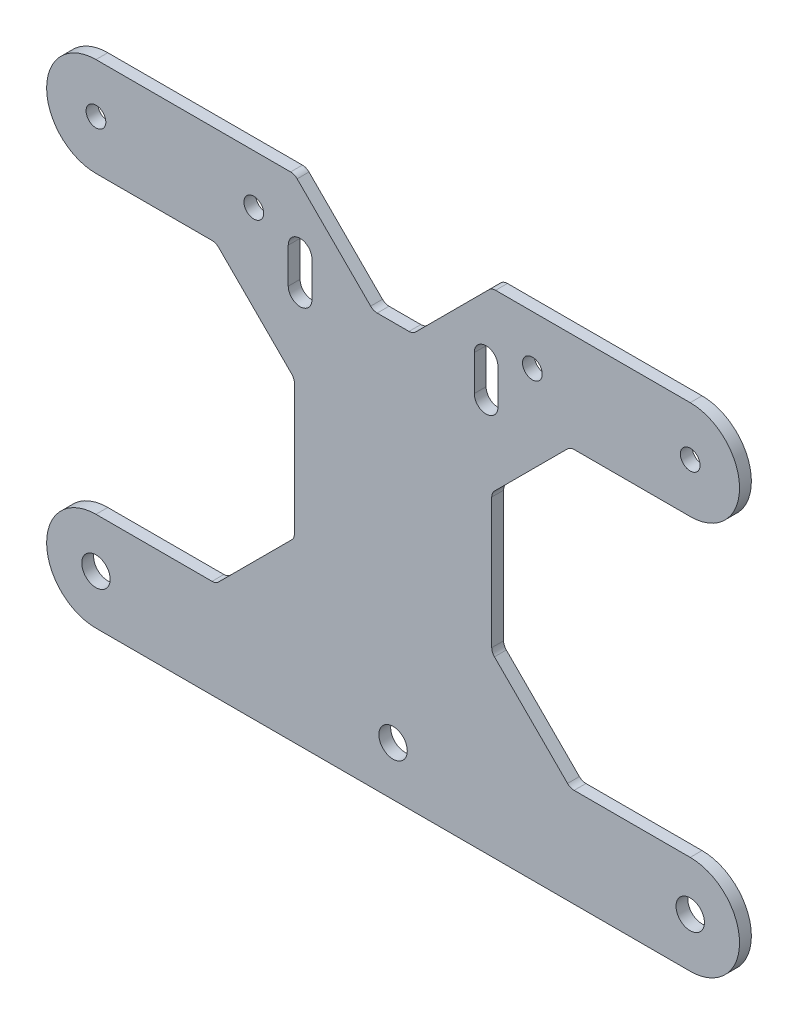
from build123d import *

# Parameters (mm, degrees)
MODEL_R             = 3.6
MODEL_R_2           = 2.5
BOSS_EXTRUDE1_DEPTH = 3


with BuildPart() as part:
    # Model → Boss-Extrude1 (new body)
    with BuildSketch(Plane.XY):
        with BuildLine():
            Line((-75.3, 0), (75.3, 0))
            ThreePointArc((75.3, 0), (87.8, 12.5), (75.3, 25))
            Line((75.3, 25), (45.873401872, 25))
            ThreePointArc((45.873401872, 25), (44.974095806, 25.178883099), (44.211700936, 25.688299064))
            Line((44.211700936, 25.688299064), (25.688299064, 44.211700936))
            ThreePointArc((25.688299064, 44.211700936), (25.178883099, 44.974095805), (25, 45.873401872))
            Line((25, 45.873401872), (25, 78.926598129))
            ThreePointArc((25, 78.926598129), (25.178883099, 79.825904195), (25.688299064, 80.588299064))
            Line((25.688299064, 80.588299064), (44.211700936, 99.111700936))
            ThreePointArc((44.211700936, 99.111700936), (44.974095806, 99.621116901), (45.873401872, 99.8))
            Line((45.873401872, 99.8), (75.3, 99.8))
            ThreePointArc((75.3, 99.8), (87.8, 112.3), (75.3, 124.8))
            Line((75.3, 124.8), (25.973401872, 124.8))
            ThreePointArc((25.973401872, 124.8), (25.074095806, 124.621116901), (24.311700936, 124.111700936))
            Line((24.311700936, 124.111700936), (5.688299064, 105.488299064))
            ThreePointArc((5.688299064, 105.488299064), (4.925904195, 104.978883099), (4.026598129, 104.8))
            Line((4.026598129, 104.8), (-4.026598129, 104.8))
            ThreePointArc((-4.026598129, 104.8), (-4.925904195, 104.978883099), (-5.688299064, 105.488299064))
            Line((-5.688299064, 105.488299064), (-24.311700936, 124.111700936))
            ThreePointArc((-24.311700936, 124.111700936), (-25.074095806, 124.621116901), (-25.973401872, 124.8))
            Line((-25.973401872, 124.8), (-75.3, 124.8))
            ThreePointArc((-75.3, 124.8), (-87.8, 112.3), (-75.3, 99.8))
            Line((-75.3, 99.8), (-45.873401872, 99.8))
            ThreePointArc((-45.873401872, 99.8), (-44.974095806, 99.621116901), (-44.211700936, 99.111700936))
            Line((-44.211700936, 99.111700936), (-25.688299064, 80.588299064))
            ThreePointArc((-25.688299064, 80.588299064), (-25.178883099, 79.825904195), (-25, 78.926598129))
            Line((-25, 78.926598129), (-25, 45.873401872))
            ThreePointArc((-25, 45.873401872), (-25.178883099, 44.974095805), (-25.688299064, 44.211700936))
            Line((-25.688299064, 44.211700936), (-44.211700936, 25.688299064))
            ThreePointArc((-44.211700936, 25.688299064), (-44.974095806, 25.178883099), (-45.873401872, 25))
            Line((-45.873401872, 25), (-75.3, 25))
            ThreePointArc((-75.3, 25), (-87.8, 12.5), (-75.3, 0))
        make_face()
        with Locations((75.3, 12.5)):
            Circle(MODEL_R, mode=Mode.SUBTRACT)
        with Locations((0, 12.5)):
            Circle(MODEL_R, mode=Mode.SUBTRACT)
        with Locations((-75.3, 12.5)):
            Circle(MODEL_R, mode=Mode.SUBTRACT)
        with Locations((-35.3, 112.3)):
            Circle(MODEL_R_2, mode=Mode.SUBTRACT)
        with Locations((-75.3, 112.3)):
            Circle(MODEL_R_2, mode=Mode.SUBTRACT)
        with Locations((35.3, 112.3)):
            Circle(MODEL_R_2, mode=Mode.SUBTRACT)
        with Locations((75.3, 112.3)):
            Circle(MODEL_R_2, mode=Mode.SUBTRACT)
        with BuildLine():
            Line((26.57, 99.43), (26.57, 108.43))
            ThreePointArc((26.57, 108.43), (23.57, 111.43), (20.57, 108.43))
            Line((20.57, 108.43), (20.57, 99.43))
            ThreePointArc((20.57, 99.43), (23.57, 96.43), (26.57, 99.43))
        make_face(mode=Mode.SUBTRACT)
        with BuildLine():
            Line((-26.57, 99.43), (-26.57, 108.43))
            ThreePointArc((-26.57, 108.43), (-23.57, 111.43), (-20.57, 108.43))
            Line((-20.57, 108.43), (-20.57, 99.43))
            ThreePointArc((-20.57, 99.43), (-23.57, 96.43), (-26.57, 99.43))
        make_face(mode=Mode.SUBTRACT)
    extrude(amount=BOSS_EXTRUDE1_DEPTH)


solid = part.part
